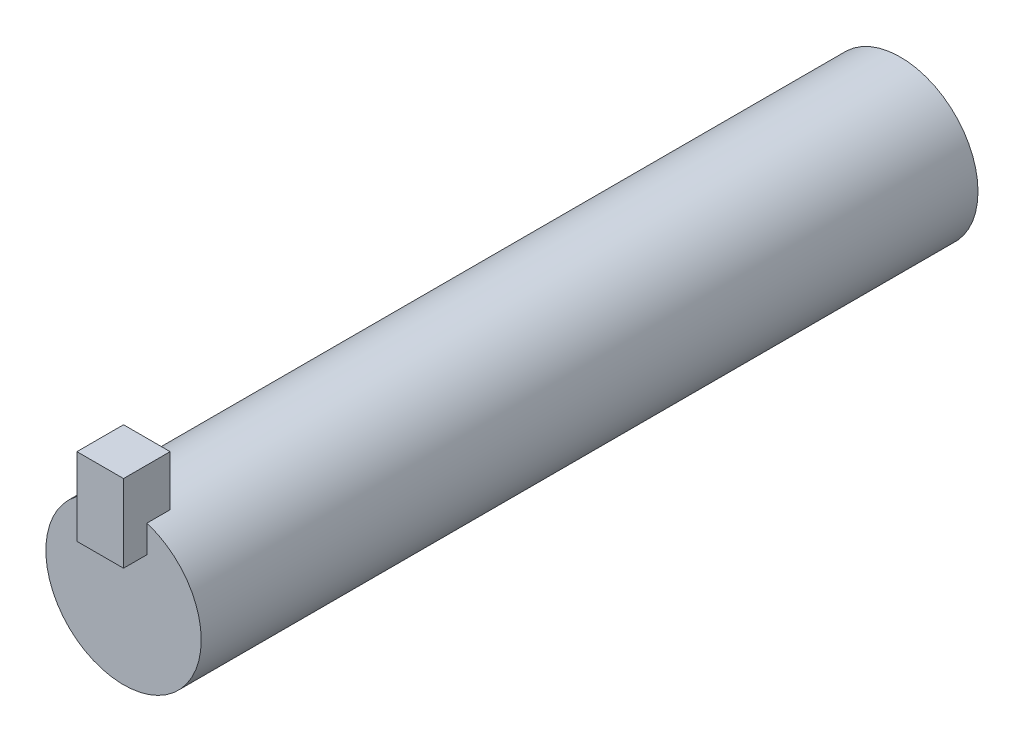
from build123d import *

# Parameters (mm, degrees)
SKIZZE1_R                            = 5
AUFSATZ_LINEAR_AUSTRAGEN1_DEPTH      = 50
SKIZZE8_W                            = 3
SKIZZE8_H                            = 3
AUFSATZ_LINEAR_AUSTRAGEN3_DEPTH      = 3
AUFSATZ_LINEAR_AUSTRAGEN3_DEPTH_BACK = 2


with BuildPart() as part:
    # Skizze1 → Aufsatz-Linear austragen1 (new body)
    with BuildSketch(Plane.XY):
        Circle(SKIZZE1_R)
    extrude(amount=AUFSATZ_LINEAR_AUSTRAGEN1_DEPTH)


with BuildPart() as body_2:
    # Skizze8 → Aufsatz-Linear austragen3 (new body, two sides)
    with BuildSketch(Plane(origin=(0, 5, 0), x_dir=(1, 0, 0), z_dir=(0, 1, 0))) as aufsatz_linear_austragen3_sk:
        with Locations((0, -50)):
            Rectangle(SKIZZE8_W, SKIZZE8_H)
    extrude(amount=AUFSATZ_LINEAR_AUSTRAGEN3_DEPTH)
    extrude(aufsatz_linear_austragen3_sk.sketch, amount=-AUFSATZ_LINEAR_AUSTRAGEN3_DEPTH_BACK)


solid = Compound([part.part, body_2.part])
